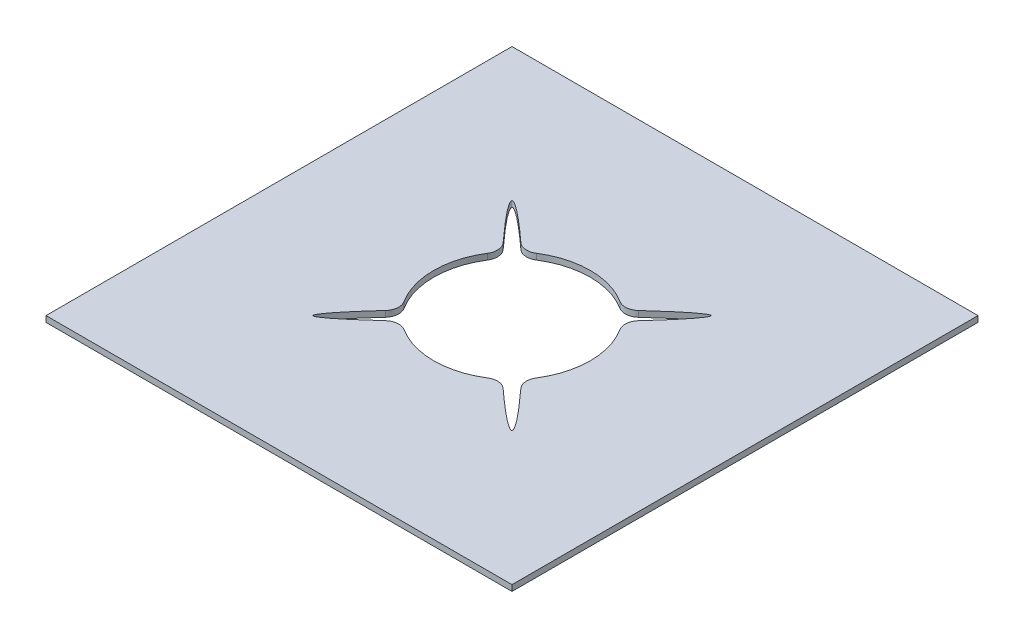
from build123d import *

# Parameters (mm, degrees)
SKETCH1_W           = 500
SKETCH1_H           = 500
BOSS_EXTRUDE1_DEPTH = 6.35
SKETCH2_R           = 84
CUT_EXTRUDE1_DEPTH  = 6.35
CUT_EXTRUDE2_DEPTH  = 6.35
FILLET1_R           = 15


with BuildPart() as part:
    # Sketch1 → Boss-Extrude1 (new body)
    with BuildSketch(Plane(origin=(0, 0, 0), x_dir=(1, 0, 0), z_dir=(0, 1, 0))):
        with Locations((20.161290323, -38.306451613)):
            Rectangle(SKETCH1_W, SKETCH1_H)
    extrude(amount=BOSS_EXTRUDE1_DEPTH)

    # Sketch2 → Cut-Extrude1 (cut)
    with BuildSketch(Plane(origin=(0, 6.35, 0), x_dir=(1, 0, 0), z_dir=(0, 1, 0))):
        with Locations(Location((20.161290323, -38.306451613, 0), (0, 0, 270))):
            Circle(SKETCH2_R)
    extrude(amount=-CUT_EXTRUDE1_DEPTH, mode=Mode.SUBTRACT)

    # Sketch3 → Cut-Extrude2 (cut)
    with BuildSketch(Plane(origin=(0, 6.35, 0), x_dir=(1, 0, 0), z_dir=(0, 1, 0))):
        with BuildLine():
            Line((-38.161167808, 9.435852288), (-27.555823691, 20.043711457))
            add(Edge.make_bspline(
                [(-38.161167808, 9.435852288), (-209.678686167, 191.47297422), (-27.555823691, 20.043711457)],
                knots=[0, 0, 0, 1, 1, 1], degree=2, weights=[1, 0.436781609, 1]))
        make_face()
        with BuildLine():
            Line((-27.581013578, -96.628911245), (-38.188872748, -86.023567127))
            add(Edge.make_bspline(
                [(-27.581013578, -96.628911245), (-209.61813551, -268.146429603), (-38.188872748, -86.023567127)],
                knots=[0, 0, 0, 1, 1, 1], degree=2, weights=[1, 0.436781609, 1]))
        make_face()
        with BuildLine():
            Line((78.483749955, -86.048757015), (67.878405837, -96.656616184))
            add(Edge.make_bspline(
                [(78.483749955, -86.048757015), (250.001268313, -268.085878946), (67.878405837, -96.656616184)],
                knots=[0, 0, 0, 1, 1, 1], degree=2, weights=[1, 0.436781609, 1]))
        make_face()
        with BuildLine():
            Line((67.903595725, 20.016006518), (78.511454894, 9.410662401))
            add(Edge.make_bspline(
                [(67.903595725, 20.016006518), (249.940717656, 191.533524877), (78.511454894, 9.410662401)],
                knots=[0, 0, 0, 1, 1, 1], degree=2, weights=[1, 0.436781609, 1]))
        make_face()
    extrude(amount=-CUT_EXTRUDE2_DEPTH, mode=Mode.SUBTRACT)

    # Fillet1
    fillet1_edges = [part.edges().sort_by_distance(p)[0] for p in [
        (-33.927432607, 3.175, 102.574717902),
        (-44.128484725, 3.175, 92.369607499),
        (84.429555949, 3.175, 92.395175331),
        (74.224445361, 3.175, 102.596227373),
        (-44.106975254, 3.175, -15.782272163),
        (-33.901864775, 3.175, -25.983324098),
        (74.250014887, 3.175, -25.961813301),
        (84.451066746, 3.175, -15.756702637),
    ]]
    fillet(fillet1_edges, radius=FILLET1_R)


solid = part.part
